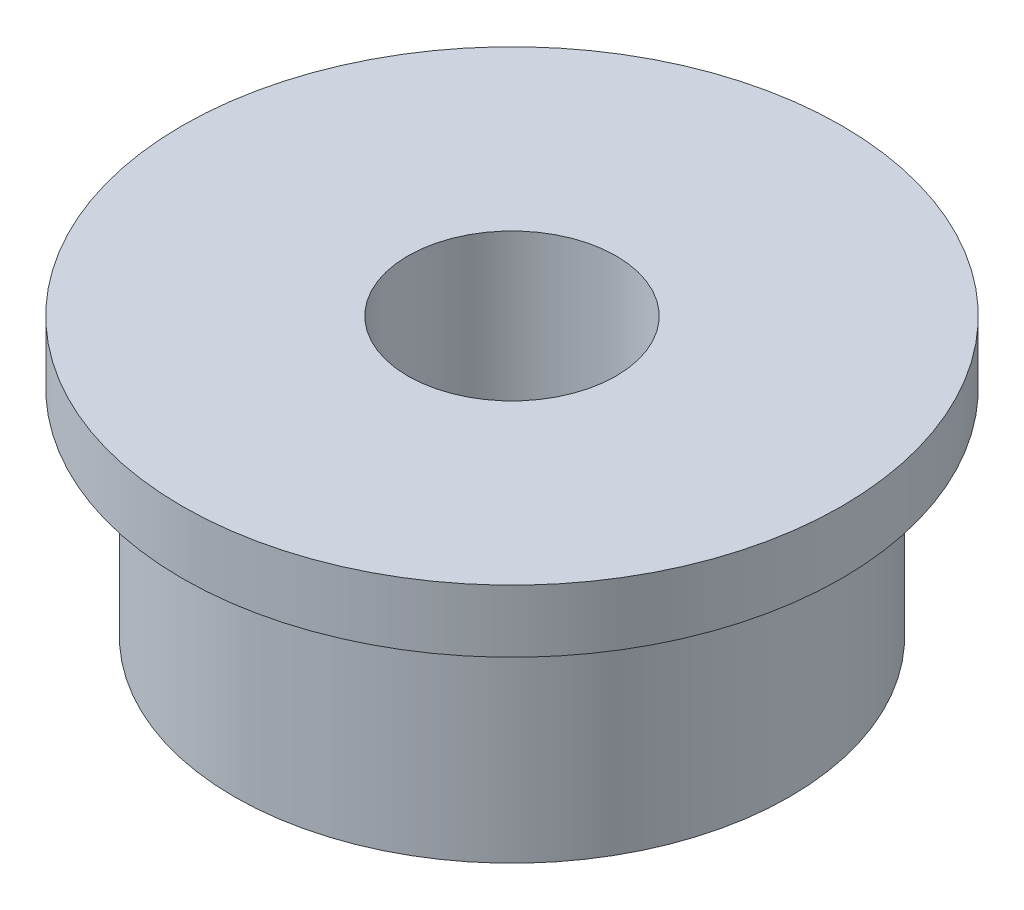
from build123d import *


with BuildPart() as part:
    # 草图1 → 旋转1 (revolve)
    with BuildSketch(Plane.XY):
        Polygon((1.5, 4), (4.75, 4), (4.75, 3.1), (4, 3.1), (4, 0), (1.5, 0), align=None)
    revolve(axis=Axis((0, 0, 0), (0, 1, 0)))


solid = part.part
